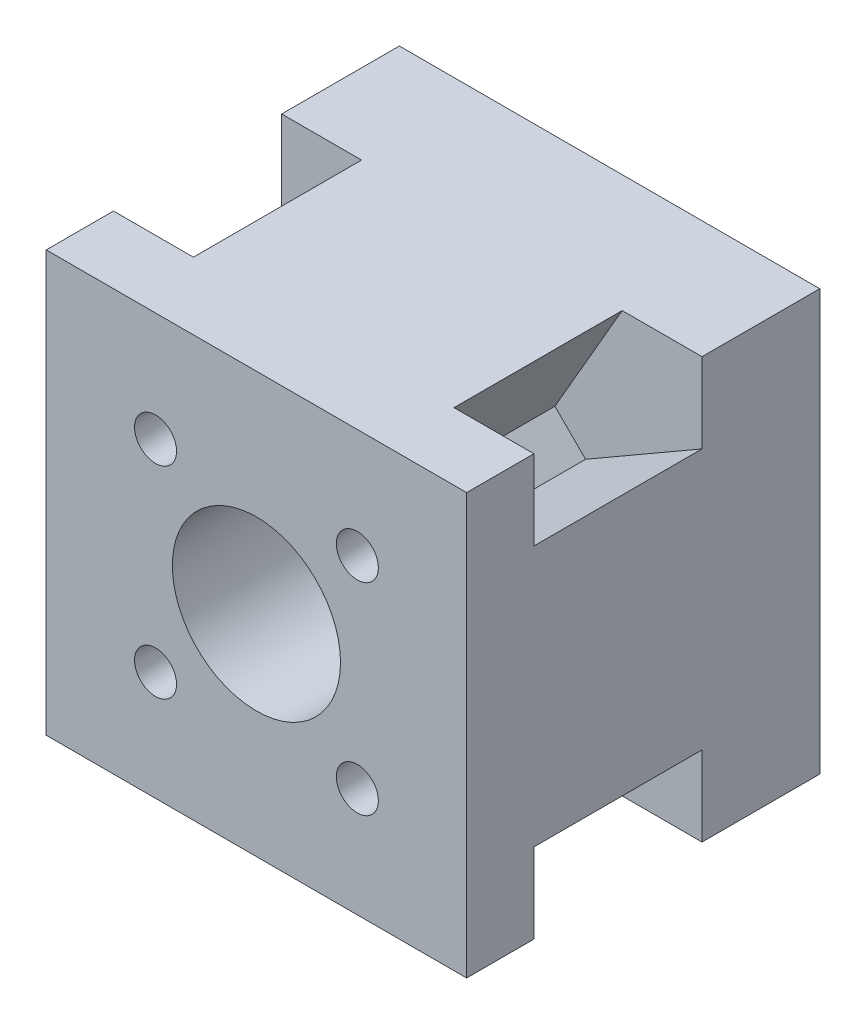
from build123d import *

# Parameters (mm, degrees)
SKETCH2_W           = 50
SKETCH2_H           = 50
BOSS_EXTRUDE2_DEPTH = 14
SKETCH4_R           = 2.75
CUT_EXTRUDE1_DEPTH  = 12
BOSS_EXTRUDE3_DEPTH = 20
SKETCH8_W           = 50
SKETCH8_H           = 50
BOSS_EXTRUDE4_DEPTH = 8
CUT_EXTRUDE3_REACH  = 56.9
CUT_EXTRUDE4_REACH  = 56.9
SKETCH10_R          = 10


with BuildPart() as part:
    # Sketch2 → Boss-Extrude2 (new body)
    with BuildSketch(Plane.XY):
        Rectangle(SKETCH2_W, SKETCH2_H)
    extrude(amount=BOSS_EXTRUDE2_DEPTH)

    # Sketch4 → Cut-Extrude1 (cut)
    with BuildSketch(Plane(origin=(0, 0, 0), x_dir=(-1, 0, 0), z_dir=(0, 0, -1))):
        with Locations((-16.5, 16.5)):
            Circle(SKETCH4_R)
        with Locations((16.5, 16.5)):
            Circle(SKETCH4_R)
        with Locations((16.5, -16.5)):
            Circle(SKETCH4_R)
        with Locations((-16.5, -16.5)):
            Circle(SKETCH4_R)
    extrude(amount=-CUT_EXTRUDE1_DEPTH, mode=Mode.SUBTRACT)

    # Sketch5 → Boss-Extrude3 (add)
    with BuildSketch(Plane.XY.offset(14)):
        Polygon((25, 15.5), (11.143593539, 7.5), (7.5, 11.143593539), (15.5, 25), (-15.5, 25), (-7.5, 11.143593539), (-11.143593539, 7.5), (-25, 15.5), (-25, -15.5), (-11.143593539, -7.5), (-7.5, -11.143593539), (-15.5, -25), (15.5, -25), (7.5, -11.143593539), (11.143593539, -7.5), (25, -15.5), align=None)
    extrude(amount=BOSS_EXTRUDE3_DEPTH)

    # Sketch8 → Boss-Extrude4 (add)
    with BuildSketch(Plane.XY.offset(34)):
        Rectangle(SKETCH8_W, SKETCH8_H)
    extrude(amount=BOSS_EXTRUDE4_DEPTH)

    # Sketch9 → Cut-Extrude3 (cut, up to next)
    with BuildSketch(Plane.XY.offset(42), mode=Mode.PRIVATE) as cut_extrude3_sk1:
        with BuildLine():
            ThreePointArc((14.5, 12), (12, 14.5), (9.5, 12))
            Line((9.5, 12), (12, 12))
            Line((12, 12), (12, 9.5))
            ThreePointArc((12, 9.5), (13.767766953, 10.232233047), (14.5, 12))
        make_face()
    cut_extrude3_tool1 = extrude(cut_extrude3_sk1.sketch, amount=-CUT_EXTRUDE3_REACH, mode=Mode.PRIVATE) & part.part
    # Sketch9 → Cut-Extrude3 (cut, up to next)
    with BuildSketch(Plane.XY.offset(42), mode=Mode.PRIVATE) as cut_extrude3_sk2:
        with BuildLine():
            Line((12, 12), (9.5, 12))
            ThreePointArc((9.5, 12), (10.232233047, 10.232233047), (12, 9.5))
            Line((12, 9.5), (12, 12))
        make_face()
    cut_extrude3_tool2 = extrude(cut_extrude3_sk2.sketch, amount=-CUT_EXTRUDE3_REACH, mode=Mode.PRIVATE) & part.part
    # Sketch9 → Cut-Extrude3 (cut, up to next)
    with BuildSketch(Plane.XY.offset(42), mode=Mode.PRIVATE) as cut_extrude3_sk3:
        with BuildLine():
            ThreePointArc((14.5, 12), (12, 14.5), (9.5, 12))
            Line((9.5, 12), (12, 12))
            Line((12, 12), (12, 9.5))
            ThreePointArc((12, 9.5), (13.767766953, 10.232233047), (14.5, 12))
        make_face()
    cut_extrude3_tool3 = extrude(cut_extrude3_sk3.sketch, amount=-CUT_EXTRUDE3_REACH, mode=Mode.PRIVATE) & part.part
    # Sketch9 → Cut-Extrude3 (cut, up to next)
    with BuildSketch(Plane.XY.offset(42), mode=Mode.PRIVATE) as cut_extrude3_sk4:
        with BuildLine():
            Line((12, 12), (9.5, 12))
            ThreePointArc((9.5, 12), (10.232233047, 10.232233047), (12, 9.5))
            Line((12, 9.5), (12, 12))
        make_face()
    cut_extrude3_tool4 = extrude(cut_extrude3_sk4.sketch, amount=-CUT_EXTRUDE3_REACH, mode=Mode.PRIVATE) & part.part
    # Sketch9 → Cut-Extrude3 (cut, up to next)
    with BuildSketch(Plane.XY.offset(42), mode=Mode.PRIVATE) as cut_extrude3_sk5:
        with BuildLine():
            ThreePointArc((14.5, -12), (13.767766953, -10.232233047), (12, -9.5))
            Line((12, -9.5), (12, -12))
            Line((12, -12), (9.5, -12))
            ThreePointArc((9.5, -12), (12, -14.5), (14.5, -12))
        make_face()
    cut_extrude3_tool5 = extrude(cut_extrude3_sk5.sketch, amount=-CUT_EXTRUDE3_REACH, mode=Mode.PRIVATE) & part.part
    # Sketch9 → Cut-Extrude3 (cut, up to next)
    with BuildSketch(Plane.XY.offset(42), mode=Mode.PRIVATE) as cut_extrude3_sk6:
        with BuildLine():
            Line((12, -12), (12, -9.5))
            ThreePointArc((12, -9.5), (10.232233047, -10.232233047), (9.5, -12))
            Line((9.5, -12), (12, -12))
        make_face()
    cut_extrude3_tool6 = extrude(cut_extrude3_sk6.sketch, amount=-CUT_EXTRUDE3_REACH, mode=Mode.PRIVATE) & part.part
    # Sketch9 → Cut-Extrude3 (cut, up to next)
    with BuildSketch(Plane.XY.offset(42), mode=Mode.PRIVATE) as cut_extrude3_sk7:
        with BuildLine():
            ThreePointArc((14.5, -12), (13.767766953, -10.232233047), (12, -9.5))
            Line((12, -9.5), (12, -12))
            Line((12, -12), (9.5, -12))
            ThreePointArc((9.5, -12), (12, -14.5), (14.5, -12))
        make_face()
    cut_extrude3_tool7 = extrude(cut_extrude3_sk7.sketch, amount=-CUT_EXTRUDE3_REACH, mode=Mode.PRIVATE) & part.part
    # Sketch9 → Cut-Extrude3 (cut, up to next)
    with BuildSketch(Plane.XY.offset(42), mode=Mode.PRIVATE) as cut_extrude3_sk8:
        with BuildLine():
            Line((12, -12), (12, -9.5))
            ThreePointArc((12, -9.5), (10.232233047, -10.232233047), (9.5, -12))
            Line((9.5, -12), (12, -12))
        make_face()
    cut_extrude3_tool8 = extrude(cut_extrude3_sk8.sketch, amount=-CUT_EXTRUDE3_REACH, mode=Mode.PRIVATE) & part.part
    # Sketch9 → Cut-Extrude3 (cut, up to next)
    with BuildSketch(Plane.XY.offset(42), mode=Mode.PRIVATE) as cut_extrude3_sk9:
        with BuildLine():
            ThreePointArc((-9.5, -12), (-10.232233047, -10.232233047), (-12, -9.5))
            Line((-12, -9.5), (-12, -12))
            Line((-12, -12), (-9.5, -12))
        make_face()
    cut_extrude3_tool9 = extrude(cut_extrude3_sk9.sketch, amount=-CUT_EXTRUDE3_REACH, mode=Mode.PRIVATE) & part.part
    # Sketch9 → Cut-Extrude3 (cut, up to next)
    with BuildSketch(Plane.XY.offset(42), mode=Mode.PRIVATE) as cut_extrude3_sk10:
        with BuildLine():
            Line((-12, -12), (-12, -9.5))
            ThreePointArc((-12, -9.5), (-13.767766953, -13.767766953), (-9.5, -12))
            Line((-9.5, -12), (-12, -12))
        make_face()
    cut_extrude3_tool10 = extrude(cut_extrude3_sk10.sketch, amount=-CUT_EXTRUDE3_REACH, mode=Mode.PRIVATE) & part.part
    # Sketch9 → Cut-Extrude3 (cut, up to next)
    with BuildSketch(Plane.XY.offset(42), mode=Mode.PRIVATE) as cut_extrude3_sk11:
        with BuildLine():
            ThreePointArc((-9.5, -12), (-10.232233047, -10.232233047), (-12, -9.5))
            Line((-12, -9.5), (-12, -12))
            Line((-12, -12), (-9.5, -12))
        make_face()
    cut_extrude3_tool11 = extrude(cut_extrude3_sk11.sketch, amount=-CUT_EXTRUDE3_REACH, mode=Mode.PRIVATE) & part.part
    # Sketch9 → Cut-Extrude3 (cut, up to next)
    with BuildSketch(Plane.XY.offset(42), mode=Mode.PRIVATE) as cut_extrude3_sk12:
        with BuildLine():
            Line((-12, -12), (-12, -9.5))
            ThreePointArc((-12, -9.5), (-13.767766953, -13.767766953), (-9.5, -12))
            Line((-9.5, -12), (-12, -12))
        make_face()
    cut_extrude3_tool12 = extrude(cut_extrude3_sk12.sketch, amount=-CUT_EXTRUDE3_REACH, mode=Mode.PRIVATE) & part.part
    # Sketch9 → Cut-Extrude3 (cut, up to next)
    with BuildSketch(Plane.XY.offset(42), mode=Mode.PRIVATE) as cut_extrude3_sk13:
        with BuildLine():
            Line((-12, 9.5), (-12, 12))
            Line((-12, 12), (-9.5, 12))
            ThreePointArc((-9.5, 12), (-13.767766953, 13.767766953), (-12, 9.5))
        make_face()
    cut_extrude3_tool13 = extrude(cut_extrude3_sk13.sketch, amount=-CUT_EXTRUDE3_REACH, mode=Mode.PRIVATE) & part.part
    # Sketch9 → Cut-Extrude3 (cut, up to next)
    with BuildSketch(Plane.XY.offset(42), mode=Mode.PRIVATE) as cut_extrude3_sk14:
        with BuildLine():
            Line((-9.5, 12), (-12, 12))
            Line((-12, 12), (-12, 9.5))
            ThreePointArc((-12, 9.5), (-10.232233047, 10.232233047), (-9.5, 12))
        make_face()
    cut_extrude3_tool14 = extrude(cut_extrude3_sk14.sketch, amount=-CUT_EXTRUDE3_REACH, mode=Mode.PRIVATE) & part.part
    # Sketch9 → Cut-Extrude3 (cut, up to next)
    with BuildSketch(Plane.XY.offset(42), mode=Mode.PRIVATE) as cut_extrude3_sk15:
        with BuildLine():
            Line((-12, 9.5), (-12, 12))
            Line((-12, 12), (-9.5, 12))
            ThreePointArc((-9.5, 12), (-13.767766953, 13.767766953), (-12, 9.5))
        make_face()
    cut_extrude3_tool15 = extrude(cut_extrude3_sk15.sketch, amount=-CUT_EXTRUDE3_REACH, mode=Mode.PRIVATE) & part.part
    # Sketch9 → Cut-Extrude3 (cut, up to next)
    with BuildSketch(Plane.XY.offset(42), mode=Mode.PRIVATE) as cut_extrude3_sk16:
        with BuildLine():
            Line((-9.5, 12), (-12, 12))
            Line((-12, 12), (-12, 9.5))
            ThreePointArc((-12, 9.5), (-10.232233047, 10.232233047), (-9.5, 12))
        make_face()
    cut_extrude3_tool16 = extrude(cut_extrude3_sk16.sketch, amount=-CUT_EXTRUDE3_REACH, mode=Mode.PRIVATE) & part.part
    add(cut_extrude3_tool1.solids().sort_by_distance((12.353678, 12.353678, 42))[0], mode=Mode.SUBTRACT)
    add(cut_extrude3_tool2.solids().sort_by_distance((10.938967, 10.938967, 42))[0], mode=Mode.SUBTRACT)
    add(cut_extrude3_tool3.solids().sort_by_distance((12.353678, 12.353678, 42))[0], mode=Mode.SUBTRACT)
    add(cut_extrude3_tool4.solids().sort_by_distance((10.938967, 10.938967, 42))[0], mode=Mode.SUBTRACT)
    add(cut_extrude3_tool5.solids().sort_by_distance((12.353678, -12.353678, 42))[0], mode=Mode.SUBTRACT)
    add(cut_extrude3_tool6.solids().sort_by_distance((10.938967, -10.938967, 42))[0], mode=Mode.SUBTRACT)
    add(cut_extrude3_tool7.solids().sort_by_distance((12.353678, -12.353678, 42))[0], mode=Mode.SUBTRACT)
    add(cut_extrude3_tool8.solids().sort_by_distance((10.938967, -10.938967, 42))[0], mode=Mode.SUBTRACT)
    add(cut_extrude3_tool9.solids().sort_by_distance((-10.938967, -10.938967, 42))[0], mode=Mode.SUBTRACT)
    add(cut_extrude3_tool10.solids().sort_by_distance((-12.353678, -12.353678, 42))[0], mode=Mode.SUBTRACT)
    add(cut_extrude3_tool11.solids().sort_by_distance((-10.938967, -10.938967, 42))[0], mode=Mode.SUBTRACT)
    add(cut_extrude3_tool12.solids().sort_by_distance((-12.353678, -12.353678, 42))[0], mode=Mode.SUBTRACT)
    add(cut_extrude3_tool13.solids().sort_by_distance((-12.353678, 12.353678, 42))[0], mode=Mode.SUBTRACT)
    add(cut_extrude3_tool14.solids().sort_by_distance((-10.938967, 10.938967, 42))[0], mode=Mode.SUBTRACT)
    add(cut_extrude3_tool15.solids().sort_by_distance((-12.353678, 12.353678, 42))[0], mode=Mode.SUBTRACT)
    add(cut_extrude3_tool16.solids().sort_by_distance((-10.938967, 10.938967, 42))[0], mode=Mode.SUBTRACT)

    # Sketch10 → Cut-Extrude4 (cut, up to next)
    with BuildSketch(Plane.XY.offset(42), mode=Mode.PRIVATE) as cut_extrude4_sk1:
        Circle(SKETCH10_R)
    cut_extrude4_tool1 = extrude(cut_extrude4_sk1.sketch, amount=-CUT_EXTRUDE4_REACH, mode=Mode.PRIVATE) & part.part
    add(cut_extrude4_tool1.solids().sort_by_distance((0, 0, 42))[0], mode=Mode.SUBTRACT)


solid = part.part
